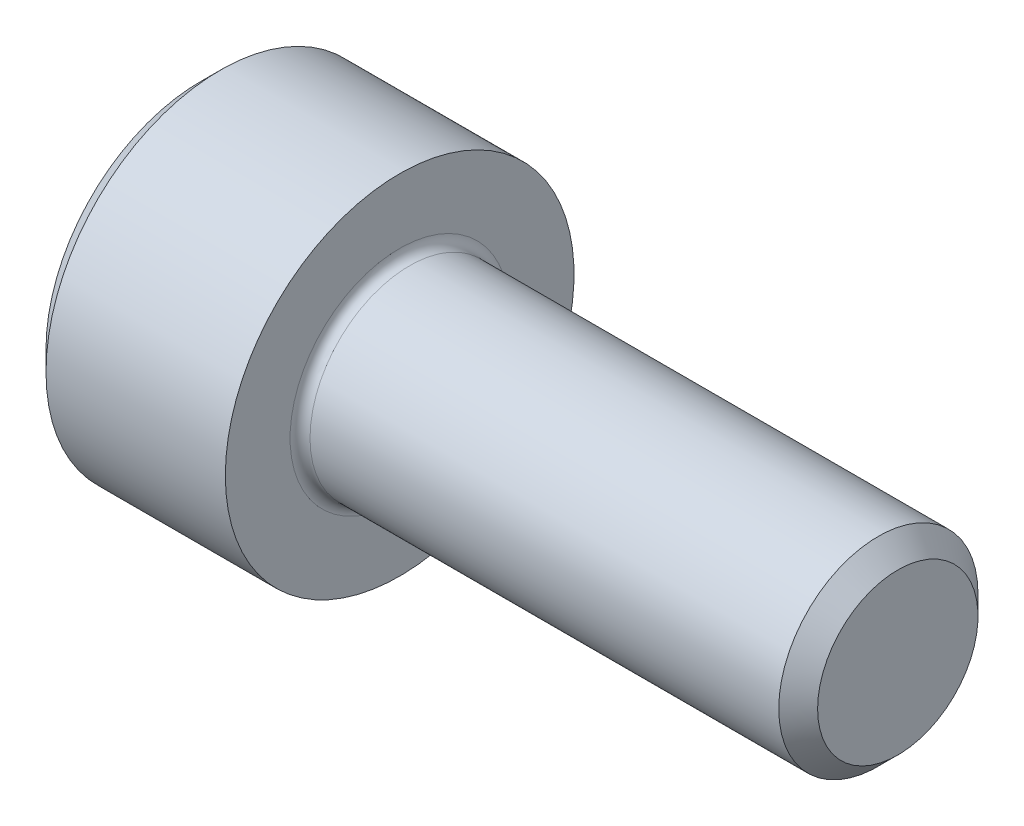
from build123d import *

# Parameters (mm, degrees)
FILLET1_R   = 0.2
HEX_2_DEPTH = 2


with BuildPart() as part:
    # BodySke → Base-Revolve (revolve)
    with BuildSketch(Plane.XY):
        Polygon((0, 0), (0, 3.1), (0.4, 3.5), (4, 3.5), (4, 2), (13.61, 2), (14, 1.61), (14, 0), align=None)
    revolve(axis=Axis((-31.75, 0, 0), (1, 0, 0)))

    # Fillet1
    fillet1_edges = [part.edges().sort_by_distance(p)[0] for p in [
        (4, -2, 0),
    ]]
    fillet(fillet1_edges, radius=FILLET1_R)

    # Sketch2 → Hex-PreBroach (revolve, cut)
    with BuildSketch(Plane.XY):
        Polygon((0, 1.5355), (2, 1.5355), (2.886521338, 0), (0, 0), align=None)
    revolve(axis=Axis((0, 0, 0), (1, 0, 0)), mode=Mode.SUBTRACT)

    # Sketch3 → Hex 2 (cut)
    with BuildSketch(Plane(origin=(0, 0, 0), x_dir=(0, 0.5, 0.866025404), z_dir=(-1, 0, 0))):
        Polygon((0.886521338, 1.5355), (-0.886521338, 1.5355), (-1.773042677, 0), (-0.886521338, -1.5355), (0.886521338, -1.5355), (1.773042677, 0), align=None)
    extrude(amount=-HEX_2_DEPTH, mode=Mode.SUBTRACT)


solid = part.part
